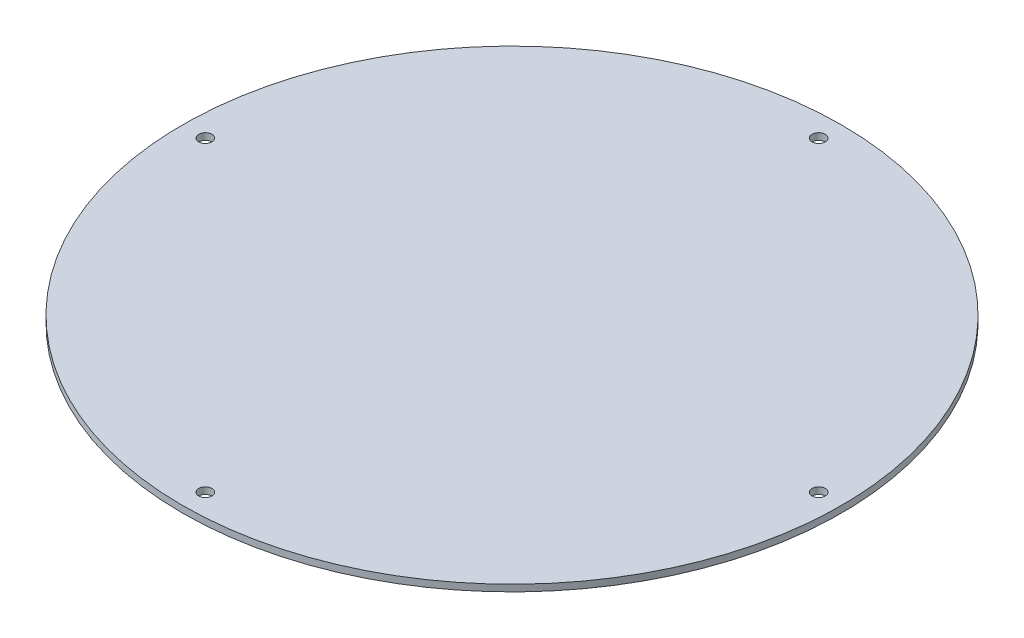
from build123d import *

# Parameters (mm, degrees)
SKETCH1_R           = 81
BOSS_EXTRUDE1_DEPTH = 1.64
SKETCH2_R           = 1.625
CUT_EXTRUDE1_DEPTH  = 2.64


with BuildPart() as part:
    # Sketch1 → Boss-Extrude1 (new body)
    with BuildSketch(Plane(origin=(0, 0, 0), x_dir=(1, 0, 0), z_dir=(0, 1, 0))):
        Circle(SKETCH1_R)
    extrude(amount=BOSS_EXTRUDE1_DEPTH)

    # Sketch2 → Cut-Extrude1 (cut, through all)
    with BuildSketch(Plane(origin=(0, 1.64, 0), x_dir=(1, 0, 0), z_dir=(0, 1, 0))):
        with Locations((0, -75.375)):
            Circle(SKETCH2_R)
        with Locations((-75.375, 0)):
            Circle(SKETCH2_R)
        with Locations((0, 75.375)):
            Circle(SKETCH2_R)
        with Locations((75.375, 0)):
            Circle(SKETCH2_R)
    extrude(amount=-CUT_EXTRUDE1_DEPTH, mode=Mode.SUBTRACT)


solid = part.part
